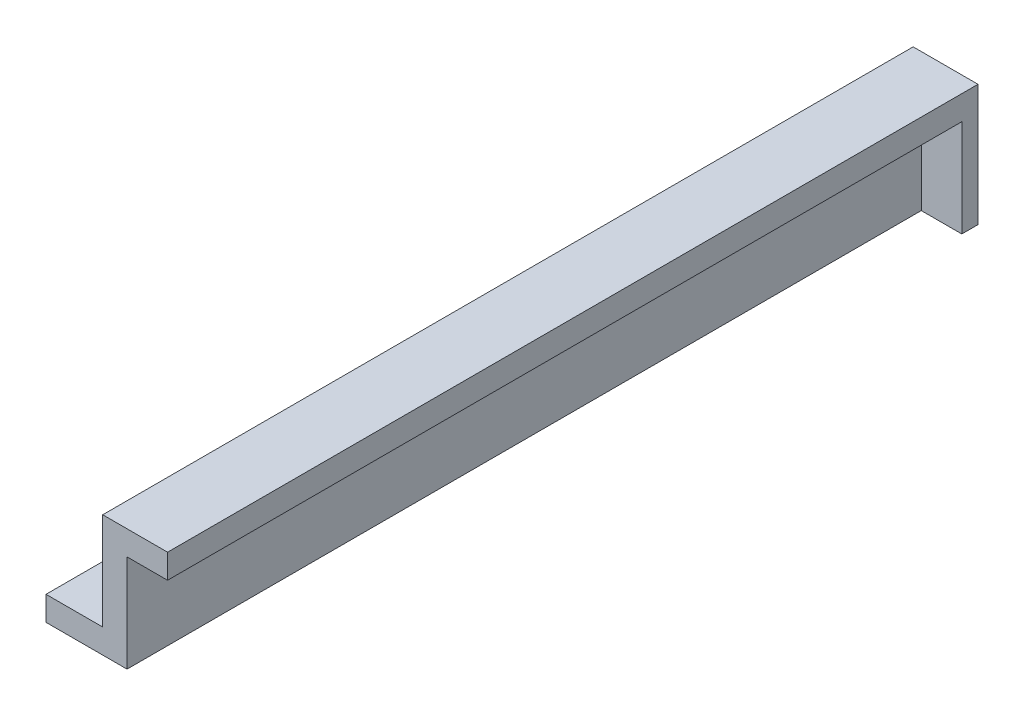
from build123d import *

# Parameters (mm, degrees)
BOSS_EXTRUDE1_DEPTH = 100
SKETCH2_R           = 2
CUT_EXTRUDE1_DEPTH  = 100
SKETCH3_W           = 5
SKETCH3_H           = 12
BOSS_EXTRUDE2_DEPTH = 2


with BuildPart() as part:
    # Sketch1 → Boss-Extrude1 (new body)
    with BuildSketch(Plane.XY):
        Polygon((0, 0), (7, 0), (7, 12), (15, 12), (15, 9), (10, 9), (10, -3), (0, -3), align=None)
    extrude(amount=BOSS_EXTRUDE1_DEPTH)

    # Sketch2 → Cut-Extrude1 (cut)
    with BuildSketch(Plane(origin=(0, 0, 0), x_dir=(1, 0, 0), z_dir=(0, 1, 0))):
        with Locations((3.5, -10)):
            Circle(SKETCH2_R)
        with Locations((3.5, -90)):
            Circle(SKETCH2_R)
        with Locations((3.5, -50)):
            Circle(SKETCH2_R)
    extrude(amount=-CUT_EXTRUDE1_DEPTH, mode=Mode.SUBTRACT)

    # Sketch3 → Boss-Extrude2 (add)
    with BuildSketch(Plane(origin=(0, 0, 0), x_dir=(-1, 0, 0), z_dir=(0, 0, -1))):
        with Locations((-12.5, 3)):
            Rectangle(SKETCH3_W, SKETCH3_H)
    extrude(amount=-BOSS_EXTRUDE2_DEPTH)


solid = part.part
